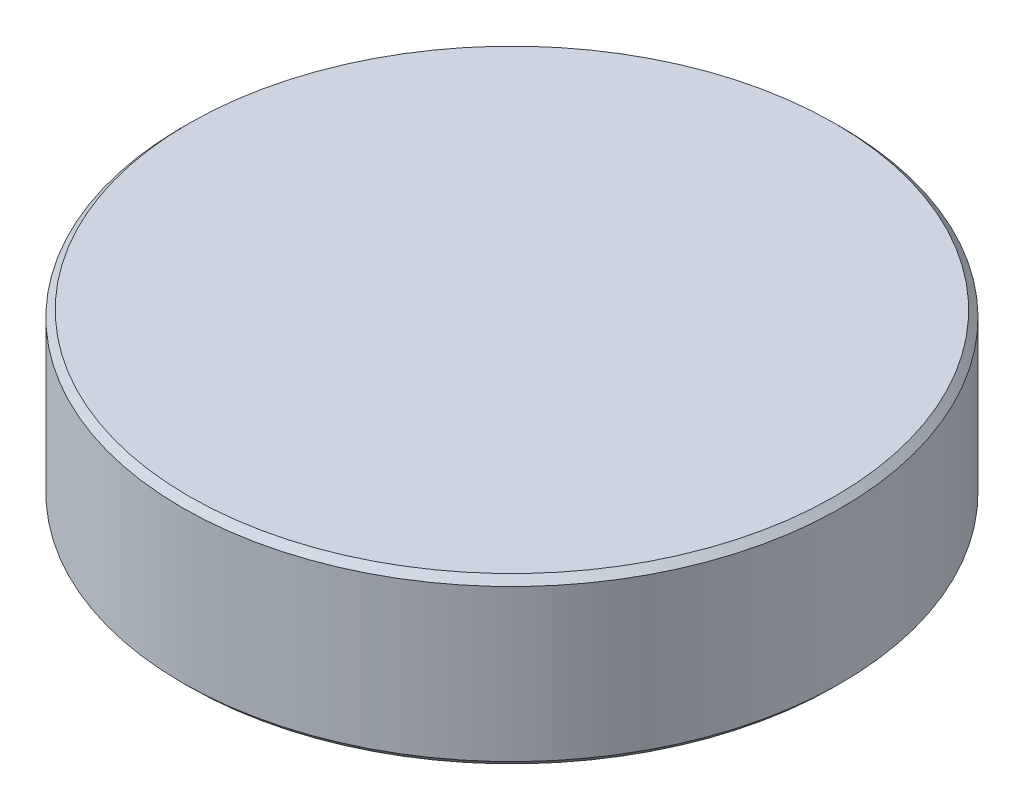
from build123d import *


with BuildPart() as part:
    # Esquisse1 → Révolution1 (revolve)
    with BuildSketch(Plane.XY):
        Polygon((-98, 25), (-100, 23), (-100, -23), (-98, -25), (0, -25), (0, 25), align=None)
    revolve(axis=Axis((0, 25, 0), (0, -1, 0)))


solid = part.part
